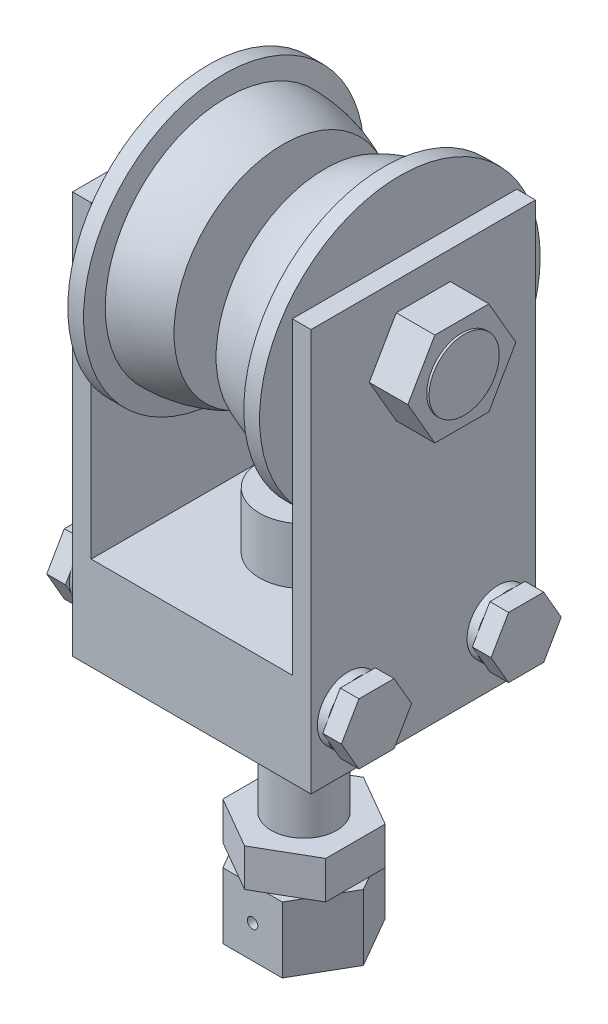
from build123d import *

# Parameters (mm, degrees)
YOKE_CROSS_SECTION_W           = 152.4
YOKE_CROSS_SECTION_H           = 63.5
YOKE_DEPTH                     = 68.2625
SIDEPLATE_PROFILE_W            = 152.4
SIDEPLATE_PROFILE_H            = 273.05
SIDEPLATE_DEPTH                = 12.7
WHEEL_PIN_NUT_DEPTH            = 26.19375
WHEEL_PIN_PROJECTION_PROFILE_R = 23.8125
WHEEL_PIN_PROJECTION_DEPTH     = 1.5875
LOCKNUTS_PROFILE_R             = 21.0947
LOCKNUTS_DEPTH                 = 6.35
SCREWS_DEPTH                   = 12.7
PROFILE_R                      = 30.1625
KING_BOLT_HEAD_DEPTH           = 38.1
DIA_R                          = 22.225
KING_BOLT_DEPTH                = 88.9
KING_BOLT_JAM_NUT_DEPTH        = 25.6286
KING_BOLT_NUT_DEPTH            = 44.6786
SKETCH5_R                      = 22.225
EXTENDED_KING_BOLT_DEPTH       = 9.525
CHAMFER1_SIZE                  = 2.38125
COTTER_PIN_HOLE_REACH          = 132.175
SKETCH7_R                      = 3.571875


with BuildPart() as part:
    # YOKE CROSS SECTION → YOKE (new body)
    with BuildSketch(Plane(origin=(0, 0, 0), x_dir=(0, 0, -1), z_dir=(1, 0, 0))):
        with Locations((0, 31.75)):
            Rectangle(YOKE_CROSS_SECTION_W, YOKE_CROSS_SECTION_H)
    extrude(amount=YOKE_DEPTH)

    # SIDEPLATE PROFILE → SIDEPLATE (add)
    with BuildSketch(Plane(origin=(68.2625, 0, 0), x_dir=(0, 0, -1), z_dir=(1, 0, 0))):
        with Locations((0, 136.525)):
            Rectangle(SIDEPLATE_PROFILE_W, SIDEPLATE_PROFILE_H)
    extrude(amount=SIDEPLATE_DEPTH)

    # WHEEL PIN NUT PROFILE → WHEEL PIN NUT (add)
    with BuildSketch(Plane(origin=(80.9625, 0, 0), x_dir=(0, 0, -1), z_dir=(1, 0, 0))):
        Polygon((36.661742094, 222.25), (18.330871047, 254), (-18.330871047, 254), (-36.661742094, 222.25), (-18.330871047, 190.5), (18.330871047, 190.5), align=None)
    extrude(amount=WHEEL_PIN_NUT_DEPTH)

    # WHEEL PIN PROJECTION PROFILE → WHEEL PIN PROJECTION (add)
    with BuildSketch(Plane(origin=(107.15625, 0, 0), x_dir=(0, 0, -1), z_dir=(1, 0, 0))):
        with Locations((0, 222.25)):
            Circle(WHEEL_PIN_PROJECTION_PROFILE_R)
    extrude(amount=WHEEL_PIN_PROJECTION_DEPTH)

    # LOCKNUTS PROFILE → LOCKNUTS (add)
    with BuildSketch(Plane(origin=(80.9625, 0, 0), x_dir=(0, 0, -1), z_dir=(1, 0, 0))):
        with Locations((-50.8, 38.1)):
            Circle(LOCKNUTS_PROFILE_R)
    locknuts = extrude(amount=LOCKNUTS_DEPTH)

    # SCREWS PROFILE → SCREWS (add)
    with BuildSketch(Plane(origin=(87.3125, 0, 0), x_dir=(0, 0, -1), z_dir=(1, 0, 0))):
        Polygon((-26.969867639, 38.1), (-38.88493382, 58.7375), (-62.71506618, 58.7375), (-74.630132361, 38.1), (-62.71506618, 17.4625), (-38.88493382, 17.4625), align=None)
    screws = extrude(amount=SCREWS_DEPTH)

    # PROFILE → KING BOLT HEAD (add)
    with BuildSketch(Plane(origin=(0, 63.5, 0), x_dir=(-1, 0, 0), z_dir=(0, 1, 0))):
        with Locations(Location((0, 0, 0), (0, 0, 90))):  # turned: the seam where the file's is
            Circle(PROFILE_R)
    extrude(amount=KING_BOLT_HEAD_DEPTH)

    # Mirror1: LOCKNUTS, SCREWS across plane
    add(locknuts.mirror(Plane.XY))
    add(screws.mirror(Plane.XY))

    # Mirror5: part across plane


with BuildPart() as part_1:
    add(part.part)
    add(part.part.mirror(Plane(origin=(0, 0, 0), x_dir=(0, 0, 1), z_dir=(1, 0, 0))))

    # DIA. → KING BOLT (add)
    with BuildSketch(Plane.XZ):
        with Locations(Location((0, 0, 0), (0, 0, 90))):  # turned: the seam where the file's is
            Circle(DIA_R)
    extrude(amount=KING_BOLT_DEPTH)

    # KING BOLT JAN NUT PROFILE → KING BOLT JAM NUT (add)
    with BuildSketch(Plane.XZ.offset(88.9)):
        Polygon((0, -40.327916303), (34.925, -20.163958151), (34.925, 20.163958151), (0, 40.327916303), (-34.925, 20.163958151), (-34.925, -20.163958151), align=None)
    extrude(amount=KING_BOLT_JAM_NUT_DEPTH)

    # KING BOLT NUT PROFILE → KING BOLT NUT (add)
    with BuildSketch(Plane.XZ.offset(114.5286)):
        Polygon((40.327916303, 0), (20.163958151, 34.925), (-20.163958151, 34.925), (-40.327916303, 0), (-20.163958151, -34.925), (20.163958151, -34.925), align=None)
    extrude(amount=KING_BOLT_NUT_DEPTH)

    # Sketch5 → EXTENDED KING BOLT (add)
    with BuildSketch(Plane.XZ.offset(159.2072)):
        with Locations(Location((0, 0, 0), (0, 0, 90))):  # turned: the seam where the file's is
            Circle(SKETCH5_R)
    extrude(amount=EXTENDED_KING_BOLT_DEPTH)

    # Chamfer1
    chamfer1_edges = [part_1.edges().sort_by_distance(p)[0] for p in [
        (0, -168.7322, -22.225),
    ]]
    chamfer(chamfer1_edges, length=CHAMFER1_SIZE)

    # Sketch6 → WHEEL (revolve)
    with BuildSketch(Plane.XY, mode=Mode.PRIVATE) as wheel_sk:
        with BuildLine():
            Line((52.3875, 304.8), (54.398982392, 317.5))
            Line((54.398982392, 317.5), (65.0875, 317.5))
            Line((65.0875, 317.5), (65.0875, 254))
            Line((65.0875, 254), (68.2625, 254))
            Line((68.2625, 254), (68.2625, 222.25))
            Line((68.2625, 222.25), (14.2875, 222.25))
            Line((14.2875, 222.25), (14.2875, 296.221852568))
            ThreePointArc((14.2875, 296.221852568), (32.860629966, 302.628953335), (52.3875, 304.8))
        make_face()
    wheel = revolve(wheel_sk.sketch.rotate(Axis((68.2625, 222.25, 0), (-1, 0, 0)), 90), axis=Axis((68.2625, 222.25, 0), (-1, 0, 0)))  # turned: the seam where the file's is

    # Mirror6: WHEEL across plane
    add(wheel.mirror(Plane(origin=(0, 0, 0), x_dir=(0, 0, 1), z_dir=(1, 0, 0))))

    # Sketch7 → COTTER PIN HOLE (cut, up to next)
    with BuildSketch(Plane.XY.offset(34.925), mode=Mode.PRIVATE) as cotter_pin_hole_sk1:
        with Locations((0, -136.9822)):
            Circle(SKETCH7_R)
    cotter_pin_hole_tool1 = extrude(cotter_pin_hole_sk1.sketch, amount=-COTTER_PIN_HOLE_REACH, mode=Mode.PRIVATE) & part_1.part
    add(cotter_pin_hole_tool1.solids().sort_by_distance((0, -136.9822, 34.925))[0], mode=Mode.SUBTRACT)


solid = part_1.part
